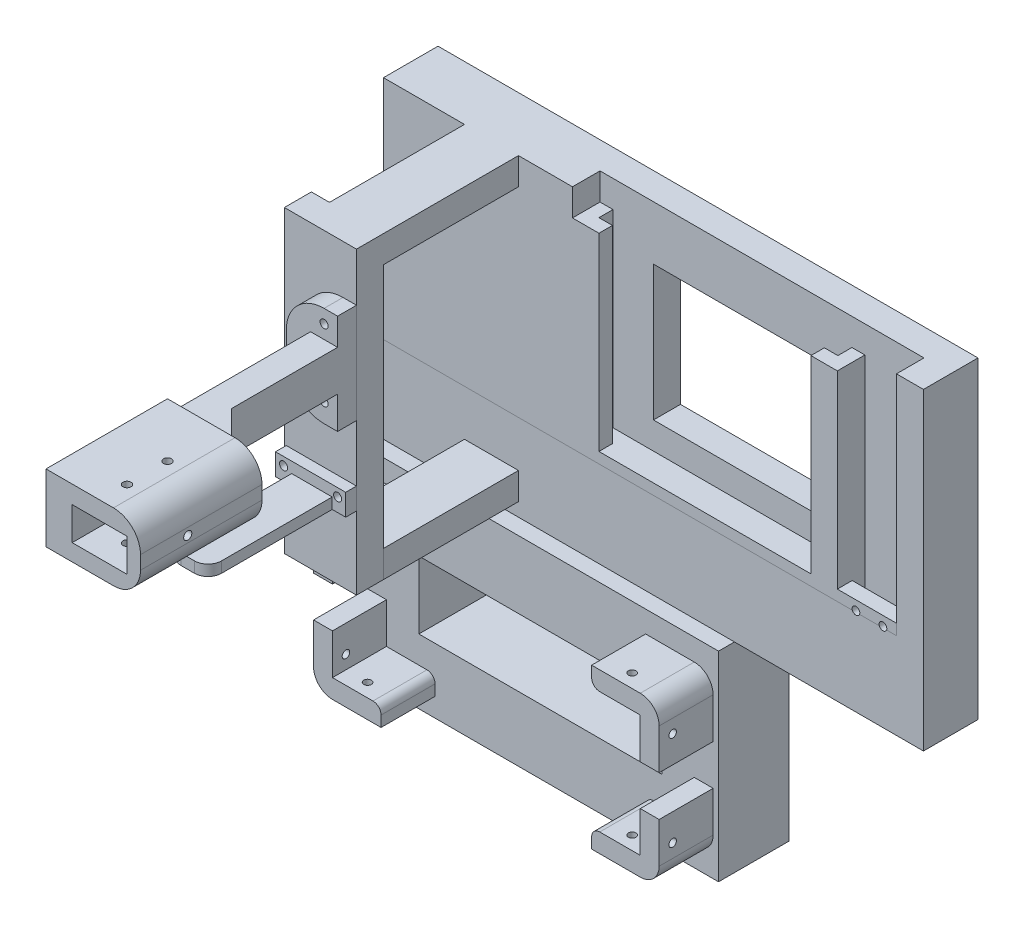
from build123d import *

# Parameters (mm, degrees)
SKETCH1_W                 = 190
SKETCH1_H                 = 80
BOSS_EXTRUDE1_DEPTH       = 10
BOSS_EXTRUDE2_DEPTH       = 70
SKETCH3_W                 = 58.5
SKETCH3_H                 = 50
CUT_EXTRUDE1_DEPTH        = 10
SKETCH5_W                 = 190
SKETCH5_H                 = 20.2
BOSS_EXTRUDE3_DEPTH       = 4
BOSS_EXTRUDE5_DEPTH       = 20.1999
SKETCH7_W                 = 200
SKETCH7_H                 = 74
SKETCH7_W_2               = 0.268020534
SKETCH7_H_2               = 19.603817147
BOSS_EXTRUDE6_DEPTH       = 5.9
SKETCH21_W                = 21.9
SKETCH21_H                = 4.7
CUT_EXTRUDE7_DEPTH        = 5.5
SKETCH22_R                = 1.425
CUT_EXTRUDE8_DEPTH        = 5.5
SKETCH23_W                = 70
SKETCH23_H                = 80
BOSS_EXTRUDE8_DEPTH       = 10.2
SKETCH24_W                = 70
SKETCH24_H                = 74
CUT_EXTRUDE9_DEPTH        = 185.949195132
SKETCH25_W                = 20
SKETCH25_H                = 10
BOSS_EXTRUDE10_DEPTH      = 50
SKETCH26_W                = 26.704510521
SKETCH26_H                = 111
BOSS_EXTRUDE11_DEPTH      = 10
BOSS_EXTRUDE12_DEPTH      = 20
SKETCH30_R                = 1.4
CUT_EXTRUDE12_DEPTH       = 60
SKETCH31_R                = 1.4
CUT_EXTRUDE13_DEPTH       = 129
SKETCH32_W                = 90
SKETCH32_H                = 25
CUT_EXTRUDE14_DEPTH       = 129
FILLET1_R                 = 7
FILLET2_R                 = 7
FILLET3_R                 = 7
FILLET4_R                 = 7
FILLET5_R                 = 3
FILLET6_R                 = 3
FILLET7_R                 = 3
FILLET8_R                 = 3
SKETCH33_W                = 15
SKETCH33_H                = 4
BOSS_EXTRUDE13_DEPTH      = 50
SKETCH36_W                = 10
SKETCH36_H                = 15
BOSS_EXTRUDE15_DEPTH      = 60
SKETCH37_W                = 35
SKETCH37_H                = 25
BOSS_EXTRUDE16_DEPTH      = 10
SKETCH38_W                = 35
SKETCH38_H                = 25
SKETCH38_W_2              = 20.3
SKETCH38_H_2              = 12.2
BOSS_EXTRUDE17_DEPTH      = 35
SKETCH39_R                = 1.5
CUT_EXTRUDE15_DEPTH       = 30
SKETCH40_R                = 1.5
CUT_EXTRUDE16_DEPTH       = 49
BOSS_EXTRUDE18_DEPTH      = 15
SKETCH42_W                = 19
SKETCH42_H                = 7
BOSS_EXTRUDE19_DEPTH      = 10
BOSS_EXTRUDE19_DEPTH_BACK = 27
FILLET9_R                 = 14
FILLET10_R                = 14
SKETCH43_R                = 1.5
CUT_EXTRUDE17_DEPTH       = 30
SKETCH44_W                = 4
SKETCH44_H                = 8
BOSS_EXTRUDE20_DEPTH      = 5
BOSS_EXTRUDE20_DEPTH_BACK = 21
SKETCH45_R                = 1.5
CUT_EXTRUDE18_DEPTH       = 20
FILLET11_R                = 5
FILLET12_R                = 5
FILLET16_R                = 10
FILLET15_R                = 10


with BuildPart() as part:
    # Sketch1 → Boss-Extrude1 (new body)
    with BuildSketch(Plane.XY):
        Rectangle(SKETCH1_W, SKETCH1_H)
    extrude(amount=BOSS_EXTRUDE1_DEPTH)

    # Sketch2 → Boss-Extrude2 (add)
    with BuildSketch(Plane.XZ.offset(40)):
        Polygon((-25, 10), (-20.2, 10), (-20.2, 15.2), (-15.2, 15.2), (-15.2, 20.2), (-25, 20.2), align=None)
        Polygon((68.3, 10), (73.1, 10), (73.1, 20.2), (63.3, 20.2), (63.3, 15.2), (68.3, 15.2), align=None)
    extrude(amount=-BOSS_EXTRUDE2_DEPTH)

    # Sketch3 → Cut-Extrude1 (cut)
    with BuildSketch(Plane.XY.offset(10)):
        with Locations((24.05, -5)):
            Rectangle(SKETCH3_W, SKETCH3_H)
    extrude(amount=-CUT_EXTRUDE1_DEPTH, mode=Mode.SUBTRACT)

    # Sketch5 → Boss-Extrude3 (add)
    with BuildSketch(Plane(origin=(0, -40, 0), x_dir=(-1, 0, 0), z_dir=(0, -1, 0))):
        with Locations((0, -10.1)):
            Rectangle(SKETCH5_W, SKETCH5_H)
    extrude(amount=BOSS_EXTRUDE3_DEPTH)

    # Sketch6 → Boss-Extrude5 (add)
    with BuildSketch(Plane(origin=(0, 0, 0), x_dir=(-1, 0, 0), z_dir=(0, 0, -1))):
        Polygon((95, -150), (95, -44), (-95, -44), (-95, 40), (-105, 40), (-105, -150), align=None)
    extrude(amount=-BOSS_EXTRUDE5_DEPTH)

    # Sketch7 → Boss-Extrude6 (add)
    with BuildSketch(Plane.XY.offset(20.1999)):
        with Locations((5, -113)):
            Rectangle(SKETCH7_W, SKETCH7_H)
        with Locations((70.627340548, -99.185279167)):
            Rectangle(SKETCH7_W_2, SKETCH7_H_2, mode=Mode.SUBTRACT)
    extrude(amount=BOSS_EXTRUDE6_DEPTH)

    # Sketch21 → Cut-Extrude7 (cut)
    with BuildSketch(Plane(origin=(0, -40, 0), x_dir=(1, 0, 0), z_dir=(0, 1, 0))):
        with Locations((84.05, -12.35)):
            Rectangle(SKETCH21_W, SKETCH21_H)
    extrude(amount=-CUT_EXTRUDE7_DEPTH, mode=Mode.SUBTRACT)

    # Sketch22 → Cut-Extrude8 (cut)
    with BuildSketch(Plane.XY.offset(20.2)):
        with Locations((90, -43.5)):
            Circle(SKETCH22_R)
        with Locations((80, -43.5)):
            Circle(SKETCH22_R)
    extrude(amount=-CUT_EXTRUDE8_DEPTH, mode=Mode.SUBTRACT)

    # Sketch23 → Boss-Extrude8 (add)
    with BuildSketch(Plane.XY.offset(10)):
        with Locations((-60, 0)):
            Rectangle(SKETCH23_W, SKETCH23_H)
    extrude(amount=BOSS_EXTRUDE8_DEPTH)

    # Sketch24 → Cut-Extrude9 (cut, through all)
    with BuildSketch(Plane.XY.offset(26.0999)):
        with Locations((70, -113)):
            Rectangle(SKETCH24_W, SKETCH24_H)
    extrude(amount=-CUT_EXTRUDE9_DEPTH, mode=Mode.SUBTRACT)

    # Sketch25 → Boss-Extrude10 (add)
    with BuildSketch(Plane.XY.offset(20.2)):
        with Locations((-55, 35)):
            Rectangle(SKETCH25_W, SKETCH25_H)
        with Locations((-55, -66)):
            Rectangle(SKETCH25_W, SKETCH25_H)
    extrude(amount=BOSS_EXTRUDE10_DEPTH)


with BuildPart() as boss_extrude10_piece_1:
    # of the separate pieces the step leaves, piece 1, a body of its own (boss_extrude10_pieces)
    add(part.part.solids().sort_by_distance((-95, 40, 20.2))[0])

    # Sketch26 → Boss-Extrude11 (add)
    with BuildSketch(Plane.XY.offset(70.2)):
        with Locations((-58.352255261, -15.5)):
            Rectangle(SKETCH26_W, SKETCH26_H)
    extrude(amount=BOSS_EXTRUDE11_DEPTH)

    # Sketch29 → Boss-Extrude12 (add)
    with BuildSketch(Plane.XY.offset(26.0999)):
        Polygon((-70, -91), (-70, -84), (-95, -84), (-95, -106), (-88, -106), (-88, -91), align=None)
        Polygon((33, -84), (8, -84), (8, -91), (26, -91), (26, -106), (33, -106), align=None)
        Polygon((33, -121), (26, -121), (26, -136), (8, -136), (8, -143), (33, -143), align=None)
        Polygon((-88, -136), (-88, -121), (-95, -121), (-95, -143), (-70, -143), (-70, -136), align=None)
    extrude(amount=BOSS_EXTRUDE12_DEPTH)

    # Sketch30 → Cut-Extrude12 (cut)
    with BuildSketch(Plane.XZ.offset(143)):
        with Locations(Location((18, 41.0999, 0), (0, 0, 270))):
            Circle(SKETCH30_R)
        with Locations(Location((-80, 41.0999, 0), (0, 0, 270))):
            Circle(SKETCH30_R)
    extrude(amount=-CUT_EXTRUDE12_DEPTH, mode=Mode.SUBTRACT)

    # Sketch31 → Cut-Extrude13 (cut)
    with BuildSketch(Plane.ZY.offset(95)):
        with Locations((41.0999, -96)):
            Circle(SKETCH31_R)
        with Locations((41.0999, -131)):
            Circle(SKETCH31_R)
    extrude(amount=-CUT_EXTRUDE13_DEPTH, mode=Mode.SUBTRACT)

    # Sketch32 → Cut-Extrude14 (cut)
    with BuildSketch(Plane.XY.offset(26.0999)):
        with Locations((-31, -113.5)):
            Rectangle(SKETCH32_W, SKETCH32_H)
    extrude(amount=-CUT_EXTRUDE14_DEPTH, mode=Mode.SUBTRACT)

    # Fillet1
    fillet1_edges = [boss_extrude10_piece_1.edges().sort_by_distance(p)[0] for p in [
        (-95, -143, 36.0999),
    ]]
    fillet(fillet1_edges, radius=FILLET1_R)

    # Fillet2
    fillet2_edges = [boss_extrude10_piece_1.edges().sort_by_distance(p)[0] for p in [
        (-95, -84, 36.0999),
    ]]
    fillet(fillet2_edges, radius=FILLET2_R)

    # Fillet3
    fillet3_edges = [boss_extrude10_piece_1.edges().sort_by_distance(p)[0] for p in [
        (33, -143, 36.0999),
    ]]
    fillet(fillet3_edges, radius=FILLET3_R)

    # Fillet4
    fillet4_edges = [boss_extrude10_piece_1.edges().sort_by_distance(p)[0] for p in [
        (33, -84, 36.0999),
    ]]
    fillet(fillet4_edges, radius=FILLET4_R)

    # Fillet5
    fillet5_edges = [boss_extrude10_piece_1.edges().sort_by_distance(p)[0] for p in [
        (-70, -91, 36.0999),
    ]]
    fillet(fillet5_edges, radius=FILLET5_R)

    # Fillet6
    fillet6_edges = [boss_extrude10_piece_1.edges().sort_by_distance(p)[0] for p in [
        (-70, -136, 36.0999),
    ]]
    fillet(fillet6_edges, radius=FILLET6_R)

    # Fillet7
    fillet7_edges = [boss_extrude10_piece_1.edges().sort_by_distance(p)[0] for p in [
        (8, -91, 36.0999),
    ]]
    fillet(fillet7_edges, radius=FILLET7_R)

    # Fillet8
    fillet8_edges = [boss_extrude10_piece_1.edges().sort_by_distance(p)[0] for p in [
        (8, -136, 36.0999),
    ]]
    fillet(fillet8_edges, radius=FILLET8_R)


with BuildPart() as boss_extrude10_piece_2:
    # of the separate pieces the step leaves, piece 2, a body of its own (boss_extrude10_pieces)
    add(part.part.solids().sort_by_distance((-45, -71, 20.2))[0])


with BuildPart() as body_3:
    # Sketch33 → Boss-Extrude13 (new body)
    with BuildSketch(Plane.XY.offset(80.2)):
        with Locations((-57.5, -42)):
            Rectangle(SKETCH33_W, SKETCH33_H)
    extrude(amount=BOSS_EXTRUDE13_DEPTH)

    # Fillet11
    fillet11_edges = [body_3.edges().sort_by_distance(p)[0] for p in [
        (-65, -42, 130.2),
    ]]
    fillet(fillet11_edges, radius=FILLET11_R)

    # Fillet12
    fillet12_edges = [body_3.edges().sort_by_distance(p)[0] for p in [
        (-50, -42, 130.2),
    ]]
    fillet(fillet12_edges, radius=FILLET12_R)


with BuildPart() as body_4:
    # Sketch36 → Boss-Extrude15 (new body)
    with BuildSketch(Plane.XY.offset(80.2)):
        with Locations((-50, 4.5)):
            Rectangle(SKETCH36_W, SKETCH36_H)
    extrude(amount=BOSS_EXTRUDE15_DEPTH)

    # Sketch37 → Boss-Extrude16 (add)
    with BuildSketch(Plane.XY.offset(140.2)):
        with Locations((-37.5, 4.5)):
            Rectangle(SKETCH37_W, SKETCH37_H)
    extrude(amount=BOSS_EXTRUDE16_DEPTH)

    # Sketch38 → Boss-Extrude17 (add)
    with BuildSketch(Plane.XY.offset(150.2)):
        with Locations((-37.5, 4.5)):
            Rectangle(SKETCH38_W, SKETCH38_H)
        with Locations((-35.15, 4.3)):
            Rectangle(SKETCH38_W_2, SKETCH38_H_2, mode=Mode.SUBTRACT)
    extrude(amount=BOSS_EXTRUDE17_DEPTH)

    # Sketch39 → Cut-Extrude15 (cut)
    with BuildSketch(Plane(origin=(0, 17, 0), x_dir=(1, 0, 0), z_dir=(0, 1, 0))):
        with Locations(Location((-35, -160.2, 0), (0, 0, 270))):
            Circle(SKETCH39_R)
        with Locations(Location((-35, -175.2, 0), (0, 0, 270))):
            Circle(SKETCH39_R)
    extrude(amount=-CUT_EXTRUDE15_DEPTH, mode=Mode.SUBTRACT)

    # Sketch40 → Cut-Extrude16 (cut)
    with BuildSketch(Plane(origin=(-20, 0, 0), x_dir=(0, 0, -1), z_dir=(1, 0, 0))):
        with Locations((-167.7, 4.4)):
            Circle(SKETCH40_R)
    extrude(amount=-CUT_EXTRUDE16_DEPTH, mode=Mode.SUBTRACT)

    # Sketch41 → Boss-Extrude18 (add)
    with BuildSketch(Plane(origin=(0, 12, 0), x_dir=(1, 0, 0), z_dir=(0, 1, 0))):
        Polygon((-45, -136.547003295), (-45, -126.547003295), (-31.347003295, -140.2), (-41.347003295, -140.2), align=None)
    extrude(amount=-BOSS_EXTRUDE18_DEPTH)

    # Sketch42 → Boss-Extrude19 (add, two sides)
    with BuildSketch(Plane(origin=(0, 12, 0), x_dir=(1, 0, 0), z_dir=(0, 1, 0))) as boss_extrude19_sk:
        with Locations((-54.5, -83.7)):
            Rectangle(SKETCH42_W, SKETCH42_H)
    extrude(amount=BOSS_EXTRUDE19_DEPTH)
    extrude(boss_extrude19_sk.sketch, amount=-BOSS_EXTRUDE19_DEPTH_BACK)

    # Fillet9
    fillet9_edges = [body_4.edges().sort_by_distance(p)[0] for p in [
        (-64, 22, 83.7),
    ]]
    fillet(fillet9_edges, radius=FILLET9_R)

    # Fillet10
    fillet10_edges = [body_4.edges().sort_by_distance(p)[0] for p in [
        (-64, -15, 83.7),
    ]]
    fillet(fillet10_edges, radius=FILLET10_R)

    # Sketch43 → Cut-Extrude17 (cut)
    with BuildSketch(Plane.XY.offset(87.2)):
        with Locations((-50, 17)):
            Circle(SKETCH43_R)
        with Locations((-50, -8)):
            Circle(SKETCH43_R)
        with Locations((-60, 4.5)):
            Circle(SKETCH43_R)
    extrude(amount=-CUT_EXTRUDE17_DEPTH, mode=Mode.SUBTRACT)

    # Fillet16
    fillet16_edges = [body_4.edges().sort_by_distance(p)[0] for p in [
        (-20, -8, 162.7),
    ]]
    fillet(fillet16_edges, radius=FILLET16_R)

    # Fillet15
    fillet15_edges = [body_4.edges().sort_by_distance(p)[0] for p in [
        (-20, 17, 162.7),
    ]]
    fillet(fillet15_edges, radius=FILLET15_R)


with BuildPart() as body_5:
    # Sketch44 → Boss-Extrude20 (new, two sides)
    with BuildSketch(Plane(origin=(-50, 0, 0), x_dir=(0, 0, -1), z_dir=(1, 0, 0))) as boss_extrude20_sk:
        with Locations((-82.2, -40)):
            Rectangle(SKETCH44_W, SKETCH44_H)
    extrude(amount=BOSS_EXTRUDE20_DEPTH)
    extrude(boss_extrude20_sk.sketch, amount=-BOSS_EXTRUDE20_DEPTH_BACK)


with BuildPart() as cut_extrude18_tool:
    # Sketch45 → Cut-Extrude18 (new body)
    with BuildSketch(Plane.XY.offset(84.2)):
        with Locations((-48, -39)):
            Circle(SKETCH45_R)
        with Locations((-68, -39)):
            Circle(SKETCH45_R)
    extrude(amount=-CUT_EXTRUDE18_DEPTH)


with BuildPart() as boss_extrude10_piece_1_1:
    add(boss_extrude10_piece_1.part)

    # Cut-Extrude18: cut by cut_extrude18_tool
    add(cut_extrude18_tool.part, mode=Mode.SUBTRACT)


with BuildPart() as body_5_1:
    add(body_5.part)

    # Cut-Extrude18: cut by cut_extrude18_tool
    add(cut_extrude18_tool.part, mode=Mode.SUBTRACT)


solid = Compound([boss_extrude10_piece_2.part, body_3.part, body_4.part, boss_extrude10_piece_1_1.part, body_5_1.part])
